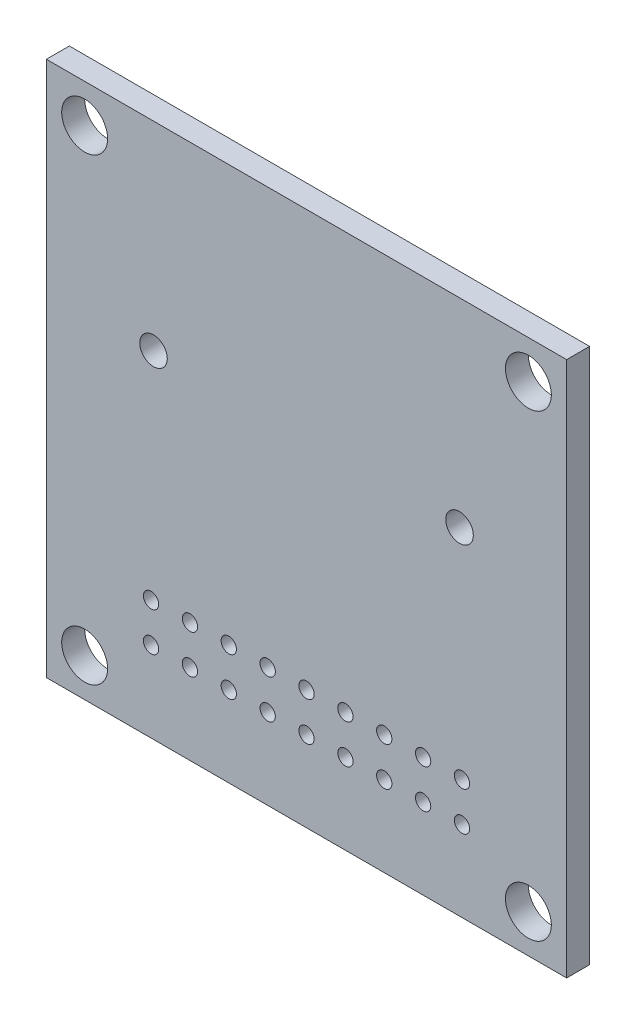
from build123d import *

# Parameters (mm, degrees)
SKETCH1_W   = 34
SKETCH1_H   = 35
SKETCH1_R   = 1.5
BOARD_DEPTH = 1.5
SKETCH2_R   = 0.9
SKETCH2_R_2 = 0.5
HOLES_DEPTH = 2


with BuildPart() as part:
    # Sketch1 → Board (new body)
    with BuildSketch(Plane.XY):
        Rectangle(SKETCH1_W, SKETCH1_H)
        with Locations((-14.5, 15)):
            Circle(SKETCH1_R, mode=Mode.SUBTRACT)
        with Locations((-14.5, -15)):
            Circle(SKETCH1_R, mode=Mode.SUBTRACT)
        with Locations((14.5, -15)):
            Circle(SKETCH1_R, mode=Mode.SUBTRACT)
        with Locations((14.5, 15)):
            Circle(SKETCH1_R, mode=Mode.SUBTRACT)
    extrude(amount=BOARD_DEPTH)

    # Sketch2 → Holes (cut)
    with BuildSketch(Plane(origin=(0, 0, 0), x_dir=(-1, 0, 0), z_dir=(0, 0, -1))):
        with Locations((-10, 4.5)):
            Circle(SKETCH2_R)
        with Locations((10, 4.5)):
            Circle(SKETCH2_R)
        with Locations((10.16, -9.69)):
            Circle(SKETCH2_R_2)
        with Locations((10.16, -12.23)):
            Circle(SKETCH2_R_2)
        with Locations((7.62, -12.23)):
            Circle(SKETCH2_R_2)
        with Locations((7.62, -9.69)):
            Circle(SKETCH2_R_2)
        with Locations((5.08, -12.23)):
            Circle(SKETCH2_R_2)
        with Locations((5.08, -9.69)):
            Circle(SKETCH2_R_2)
        with Locations((2.54, -12.23)):
            Circle(SKETCH2_R_2)
        with Locations((2.54, -9.69)):
            Circle(SKETCH2_R_2)
        with Locations((0, -12.23)):
            Circle(SKETCH2_R_2)
        with Locations((0, -9.69)):
            Circle(SKETCH2_R_2)
        with Locations((-2.54, -12.23)):
            Circle(SKETCH2_R_2)
        with Locations((-2.54, -9.69)):
            Circle(SKETCH2_R_2)
        with Locations((-5.08, -12.23)):
            Circle(SKETCH2_R_2)
        with Locations((-5.08, -9.69)):
            Circle(SKETCH2_R_2)
        with Locations((-7.62, -12.23)):
            Circle(SKETCH2_R_2)
        with Locations((-7.62, -9.69)):
            Circle(SKETCH2_R_2)
        with Locations((-10.16, -12.23)):
            Circle(SKETCH2_R_2)
        with Locations((-10.16, -9.69)):
            Circle(SKETCH2_R_2)
    extrude(amount=-HOLES_DEPTH, mode=Mode.SUBTRACT)


solid = part.part
